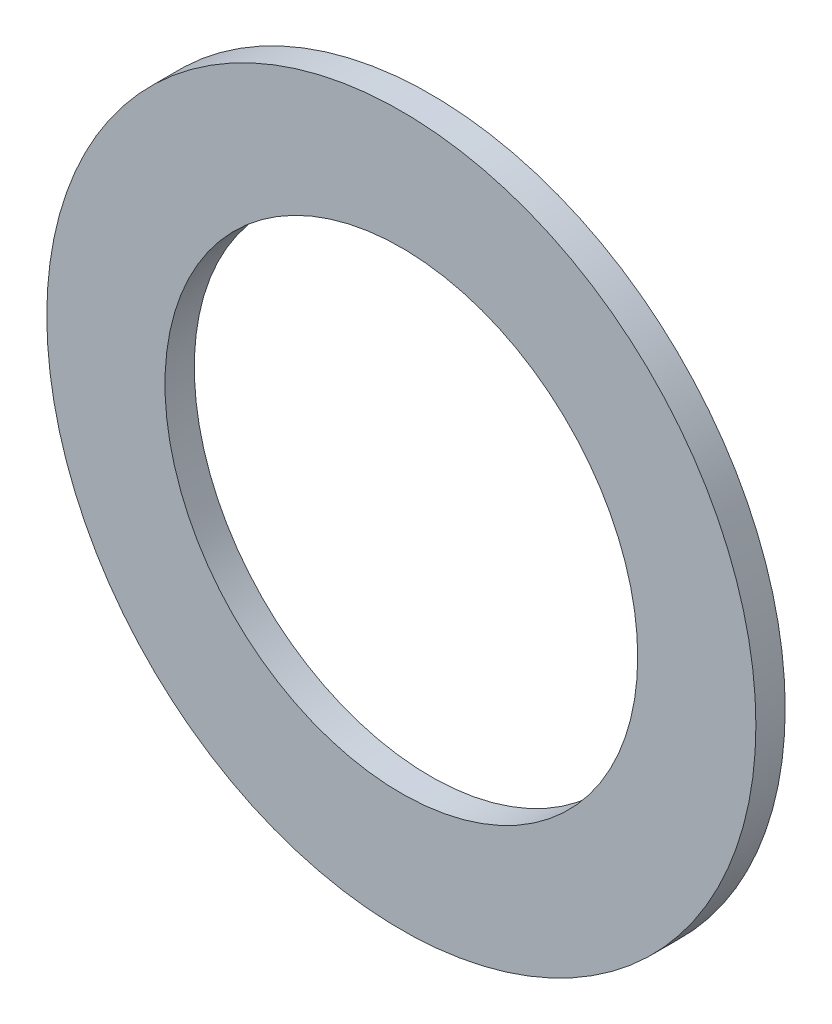
from build123d import *

# Parameters (mm, degrees)
SKETCH1_R           = 9.525
SKETCH1_R_2         = 6.35
BOSS_EXTRUDE1_DEPTH = 0.7874


with BuildPart() as part:
    # Sketch1 → Boss-Extrude1 (new body)
    with BuildSketch(Plane.XY):
        Circle(SKETCH1_R)
        Circle(SKETCH1_R_2, mode=Mode.SUBTRACT)
    extrude(amount=BOSS_EXTRUDE1_DEPTH)


solid = part.part
